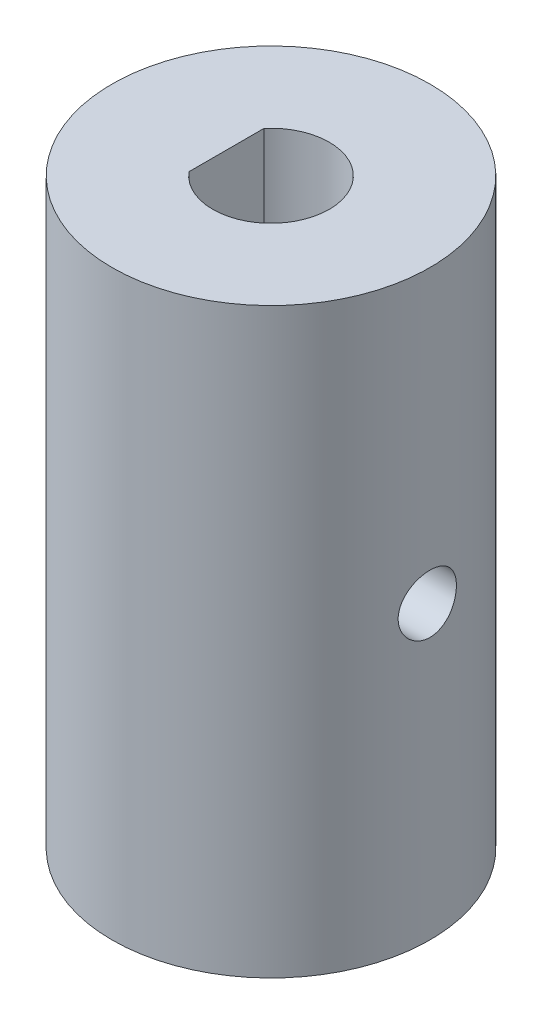
from build123d import *

# Parameters (mm, degrees)
SKETCH1_R               = 8.189006913
BOSS_EXTRUDE1_DEPTH     = 30
SKETCH2_R               = 3
CUT_EXTRUDE1_DEPTH      = 30
SKETCH4_W               = 1.839212521
SKETCH4_H               = 4.190652527
BOSS_EXTRUDE2_DEPTH     = 10
CUT_EXTRUDE2_DEPTH      = 10
CUT_EXTRUDE2_DEPTH_BACK = 10
SKETCH3_R               = 1.5


with BuildPart() as part:
    # Sketch1 → Boss-Extrude1 (new body)
    with BuildSketch(Plane(origin=(0, 0, 0), x_dir=(1, 0, 0), z_dir=(0, 1, 0))):
        Circle(SKETCH1_R)
    extrude(amount=BOSS_EXTRUDE1_DEPTH)

    # Sketch2 → Cut-Extrude1 (cut)
    with BuildSketch(Plane(origin=(0, 30, 0), x_dir=(1, 0, 0), z_dir=(0, 1, 0))):
        Circle(SKETCH2_R)
    extrude(amount=-CUT_EXTRUDE1_DEPTH, mode=Mode.SUBTRACT)

    # Sketch4 → Boss-Extrude2 (add)
    with BuildSketch(Plane(origin=(0, 30, 0), x_dir=(1, 0, 0), z_dir=(0, 1, 0))):
        with Locations((-3.214713917, 0.163363311)):
            Rectangle(SKETCH4_W, SKETCH4_H)
    extrude(amount=-BOSS_EXTRUDE2_DEPTH)

    # Sketch3 → Cut-Extrude2 (cut, two sides: drawn at the far end of the back side and taken through both)
    with BuildSketch(Plane(origin=(0, 0, 0), x_dir=(0, 0, -1), z_dir=(1, 0, 0)).offset(-CUT_EXTRUDE2_DEPTH_BACK)):
        with Locations((0, 15)):
            Circle(SKETCH3_R)
    extrude(amount=CUT_EXTRUDE2_DEPTH + CUT_EXTRUDE2_DEPTH_BACK, mode=Mode.SUBTRACT)


solid = part.part
